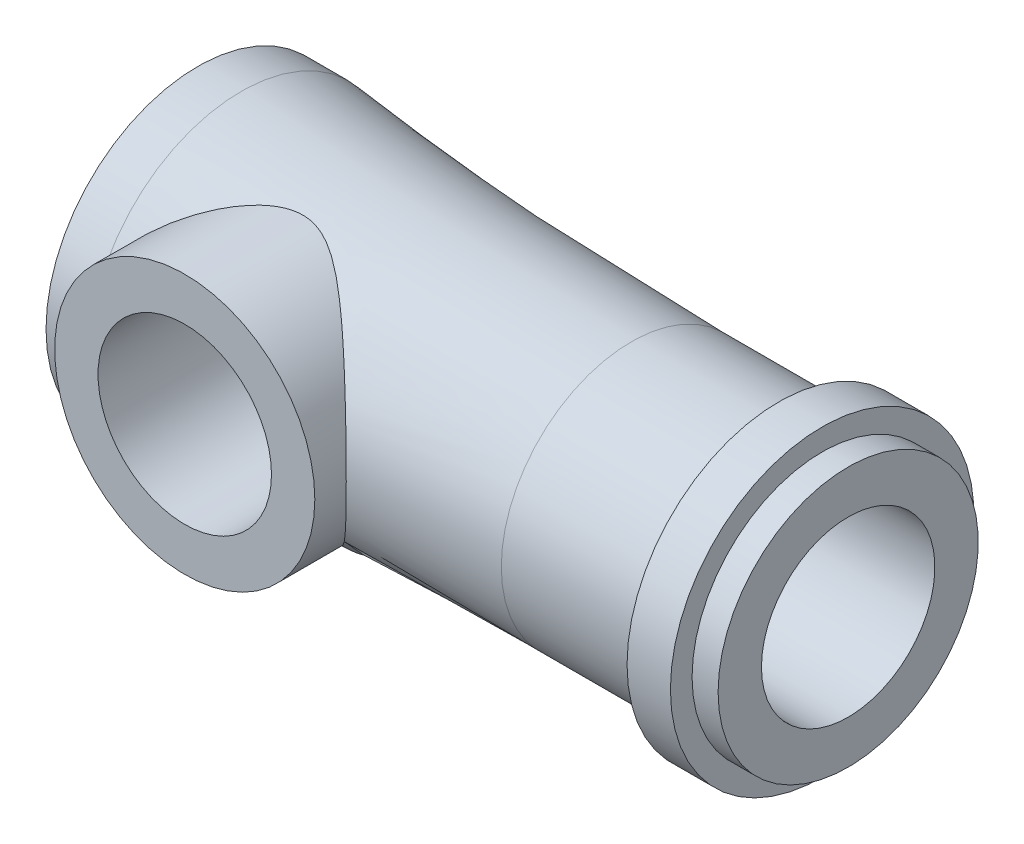
from build123d import *

# Parameters (mm, degrees)
SKETCH_2_R          = 15
EXTRUDE_1_DEPTH     = 19
SKETCH_3_R          = 10
CUT_EXTRUDE_1_DEPTH = 25


with BuildPart() as part:
    # 스케치1 → 회전1 (revolve)
    with BuildSketch(Plane.XY):
        with BuildLine():
            Line((0, 0), (0, 17.5))
            Line((0, 17.5), (5, 17.5))
            ThreePointArc((5, 17.5), (27.465304528, 15.62548151), (50, 15))
            Line((50, 15), (67, 15))
            Line((67, 15), (67, 17.5))
            Line((67, 17.5), (72, 17.5))
            Line((72, 17.5), (72, 15))
            Line((72, 15), (75, 15))
            Line((75, 15), (75, 10))
            Line((75, 10), (60, 10))
            Line((60, 10), (60, 0))
            Line((60, 0), (0, 0))
        make_face()
    revolve(axis=Axis((0, 0, 0), (1, 0, 0)))

    # 스케치2 → 보스-돌출1 (add)
    with BuildSketch(Plane.XY):
        with Locations((17.5, 0)):
            Circle(SKETCH_2_R)
    extrude(amount=EXTRUDE_1_DEPTH)

    # 스케치3 → 컷-돌출1 (cut)
    with BuildSketch(Plane.XY.offset(19)):
        with Locations((17.5, 0)):
            Circle(SKETCH_3_R)
    extrude(amount=-CUT_EXTRUDE_1_DEPTH, mode=Mode.SUBTRACT)


solid = part.part
